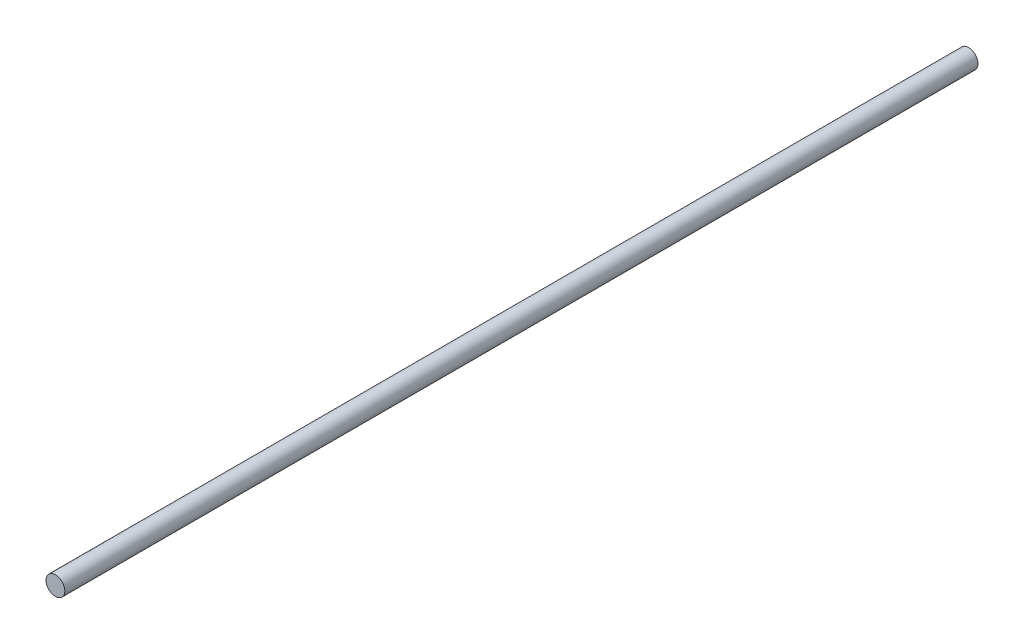
from build123d import *

# Parameters (mm, degrees)
SKETCH_1_R      = 3
EXTRUDE_1_DEPTH = 291.2


with BuildPart() as part:
    # 草图1 → 凸台-拉伸1 (new body)
    with BuildSketch(Plane.XY):
        Circle(SKETCH_1_R)
    extrude(amount=EXTRUDE_1_DEPTH)


solid = part.part
